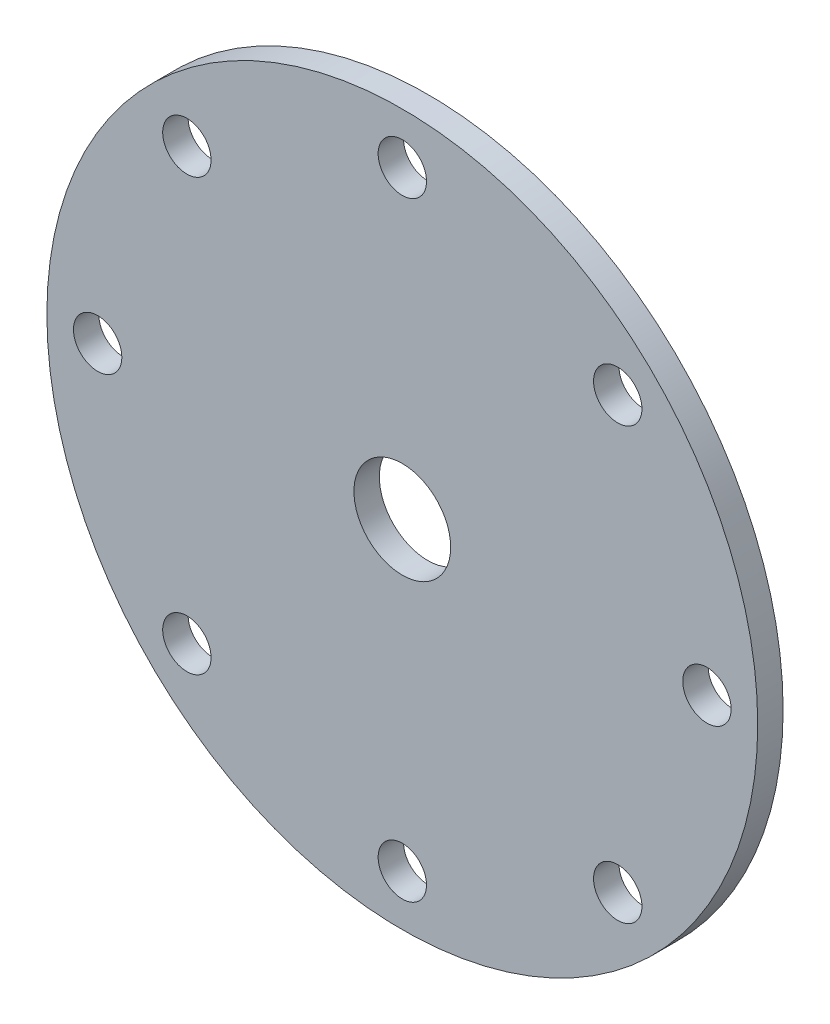
from build123d import *

# Parameters (mm, degrees)
SKETCH1_R        = 70
SKETCH1_R_2      = 9.525
SKETCH1_R_3      = 4.7625
ROTOR_DISC_DEPTH = 5


with BuildPart() as part:
    # Sketch1 → Rotor Disc (new body)
    with BuildSketch(Plane.XY):
        Circle(SKETCH1_R)
        Circle(SKETCH1_R_2, mode=Mode.SUBTRACT)
        with Locations((0, 60)):
            Circle(SKETCH1_R_3, mode=Mode.SUBTRACT)
        with Locations((42.426406871, 42.426406871)):
            Circle(SKETCH1_R_3, mode=Mode.SUBTRACT)
        with Locations((60, 0)):
            Circle(SKETCH1_R_3, mode=Mode.SUBTRACT)
        with Locations((42.426406871, -42.426406871)):
            Circle(SKETCH1_R_3, mode=Mode.SUBTRACT)
        with Locations((0, -60)):
            Circle(SKETCH1_R_3, mode=Mode.SUBTRACT)
        with Locations((-42.426406871, -42.426406871)):
            Circle(SKETCH1_R_3, mode=Mode.SUBTRACT)
        with Locations((-60, 0)):
            Circle(SKETCH1_R_3, mode=Mode.SUBTRACT)
        with Locations((-42.426406871, 42.426406871)):
            Circle(SKETCH1_R_3, mode=Mode.SUBTRACT)
    extrude(amount=ROTOR_DISC_DEPTH)


solid = part.part
